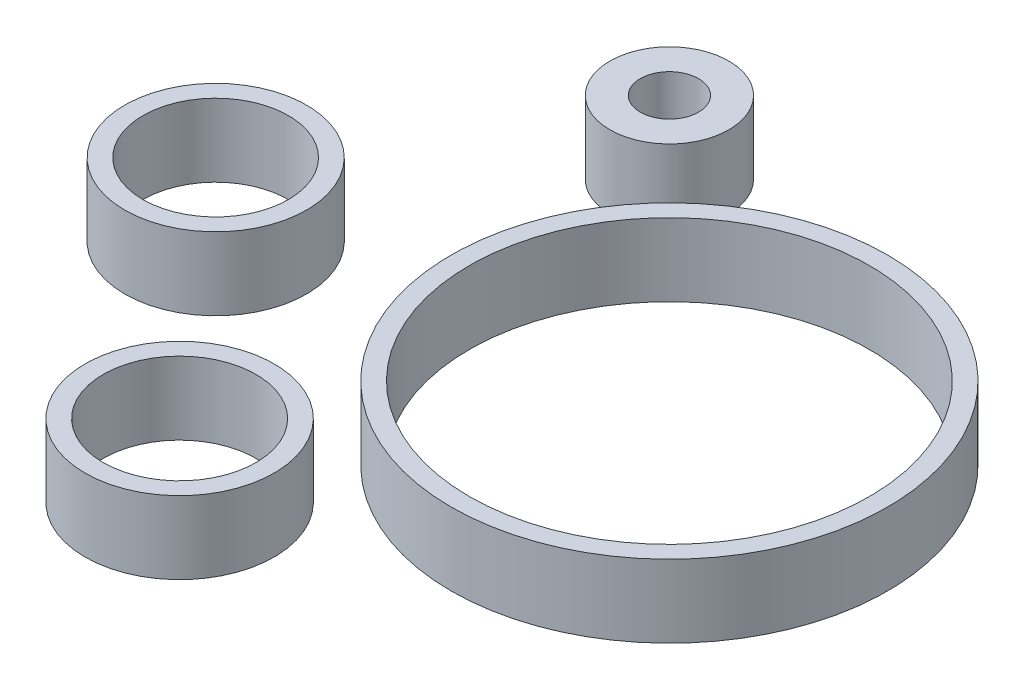
from build123d import *

# Parameters (mm, degrees)
SKETCH_1_R        = 15
SKETCH_1_R_2      = 13.75
EXTRUDE_1_DEPTH   = 5
SKETCH_1_R_3      = 6.25
SKETCH_1_R_4      = 5
EXTRUDE_1_2_DEPTH = 5
SKETCH_1_R_5      = 4.09124723
SKETCH_1_R_6      = 2
EXTRUDE_1_3_DEPTH = 5
SKETCH_1_R_7      = 6.5
SKETCH_1_R_8      = 5.25
EXTRUDE_1_4_DEPTH = 5


with BuildPart() as part:
    # 草图1 → 凸台-拉伸1 (new body)
    with BuildSketch(Plane(origin=(0, 0, 0), x_dir=(1, 0, 0), z_dir=(0, 1, 0))):
        with Locations((-12.984231372, -10.309208812)):
            Circle(SKETCH_1_R)
        with Locations((-12.984231372, -10.309208812)):
            Circle(SKETCH_1_R_2, mode=Mode.SUBTRACT)
    extrude(amount=EXTRUDE_1_DEPTH)


with BuildPart() as body_2:
    # 草图1 → Extrude 1 2 (new body)
    with BuildSketch(Plane(origin=(0, 0, 0), x_dir=(1, 0, 0), z_dir=(0, 1, 0))):
        with Locations((-41.874421892, -12.600941392)):
            Circle(SKETCH_1_R_3)
        with Locations((-41.874421892, -12.600941392)):
            Circle(SKETCH_1_R_4, mode=Mode.SUBTRACT)
    extrude(amount=EXTRUDE_1_2_DEPTH)


with BuildPart() as body_3:
    # 草图1 → Extrude 1 3 (new body)
    with BuildSketch(Plane(origin=(0, 0, 0), x_dir=(1, 0, 0), z_dir=(0, 1, 0))):
        with Locations((-29.984231372, 6.690791188)):
            Circle(SKETCH_1_R_5)
        with Locations((-29.984231372, 6.690791188)):
            Circle(SKETCH_1_R_6, mode=Mode.SUBTRACT)
    extrude(amount=EXTRUDE_1_3_DEPTH)


with BuildPart() as body_4:
    # 草图1 → Extrude 1 4 (new body)
    with BuildSketch(Plane(origin=(0, 0, 0), x_dir=(1, 0, 0), z_dir=(0, 1, 0))):
        with Locations((-27.585195105, -29.367622216)):
            Circle(SKETCH_1_R_7)
        with Locations((-27.585195105, -29.367622216)):
            Circle(SKETCH_1_R_8, mode=Mode.SUBTRACT)
    extrude(amount=EXTRUDE_1_4_DEPTH)


solid = Compound([part.part, body_2.part, body_3.part, body_4.part])
